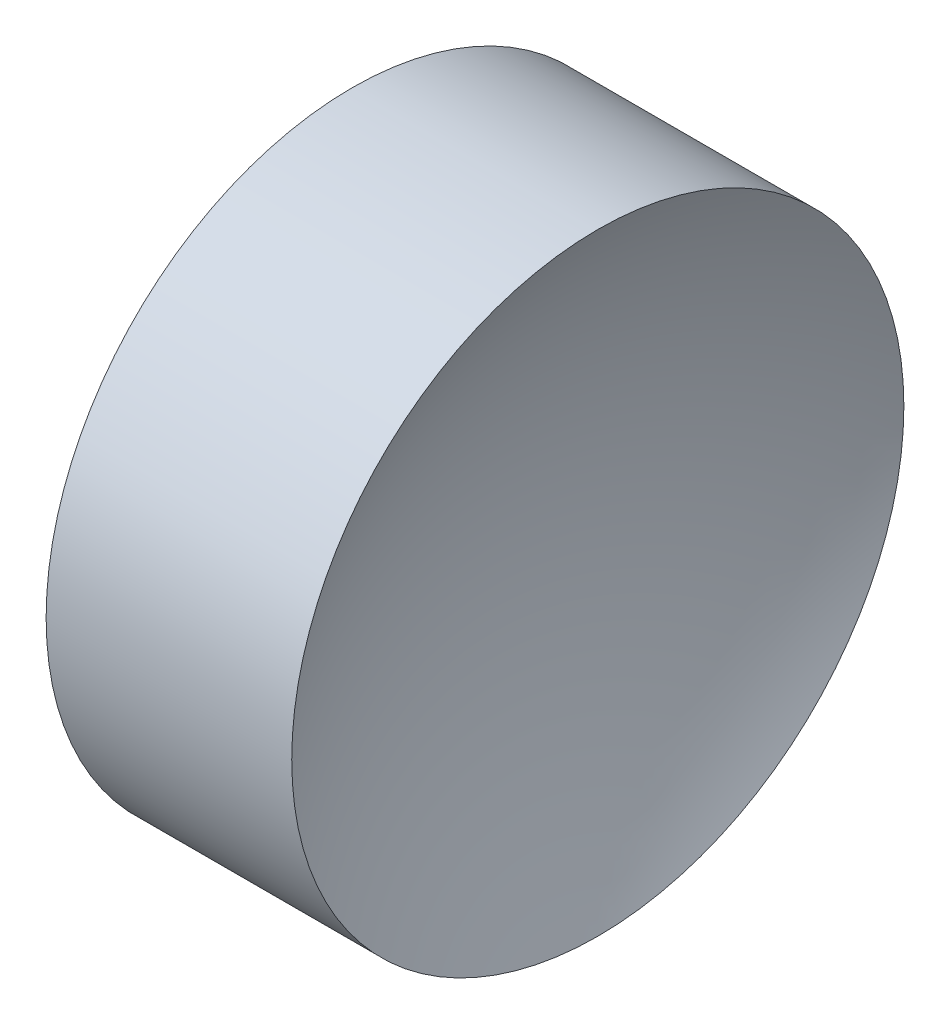
from build123d import *


with BuildPart() as part:
    # 草图1 → 旋转1 (revolve)
    with BuildSketch(Plane.XY):
        with BuildLine():
            Line((23.274256364, 13.044520575), (24.774256364, 13.044520575))
            ThreePointArc((24.774256364, 13.044520575), (25.093067515, 15.622194603), (26.030287252, 18.044520575))
            Line((26.030287252, 18.044520575), (24.024256364, 18.044520575))
            Line((24.024256364, 18.044520575), (22.018225476, 18.044520575))
            ThreePointArc((22.018225476, 18.044520575), (22.955445213, 15.622194603), (23.274256364, 13.044520575))
        make_face()
    revolve(axis=Axis((21.224930557, 13.044520575, 0), (1, 0, 0)))


solid = part.part
